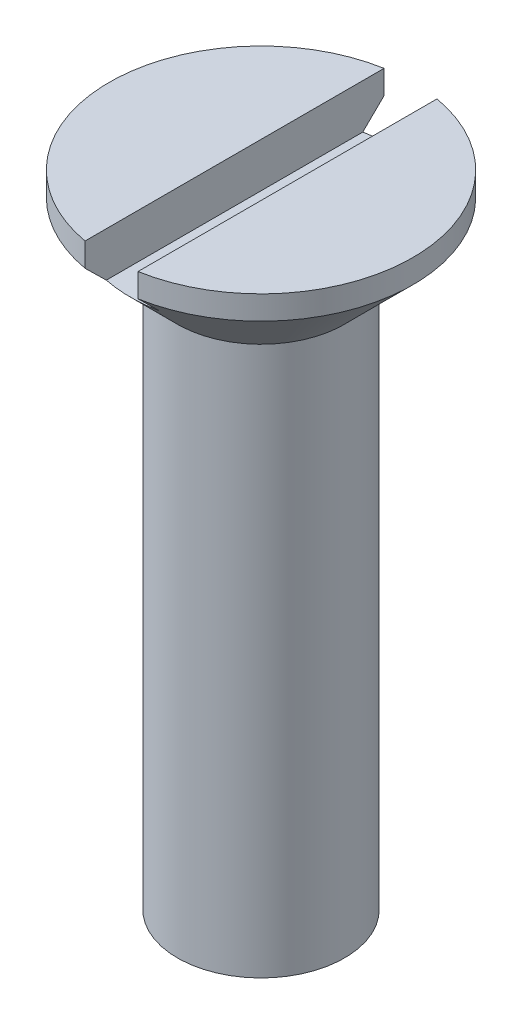
from build123d import *

# Parameters (mm, degrees)
SKETCH2_W               = 1.9
SKETCH2_H               = 3.2
CUT_EXTRUDE1_DEPTH      = 6.45
CUT_EXTRUDE1_DEPTH_BACK = 6.45


with BuildPart() as part:
    # Sketch1 → Revolve1 (revolve)
    with BuildSketch(Plane.XY):
        Polygon((0, 0), (3, 1.732050808), (3, 21.432050808), (5.45, 23.882050808), (5.45, 24.732050808), (0, 24.732050808), align=None)
    revolve(axis=Axis((0, 24.732050808, 0), (0, -1, 0)))

    # Sketch2 → Cut-Extrude1 (cut, two sides)
    with BuildSketch(Plane.XY) as cut_extrude1_sk:
        with Locations((0, 24.732050808)):
            Rectangle(SKETCH2_W, SKETCH2_H)
    extrude(amount=CUT_EXTRUDE1_DEPTH, mode=Mode.SUBTRACT)
    extrude(cut_extrude1_sk.sketch, amount=-CUT_EXTRUDE1_DEPTH_BACK, mode=Mode.SUBTRACT)


solid = part.part
